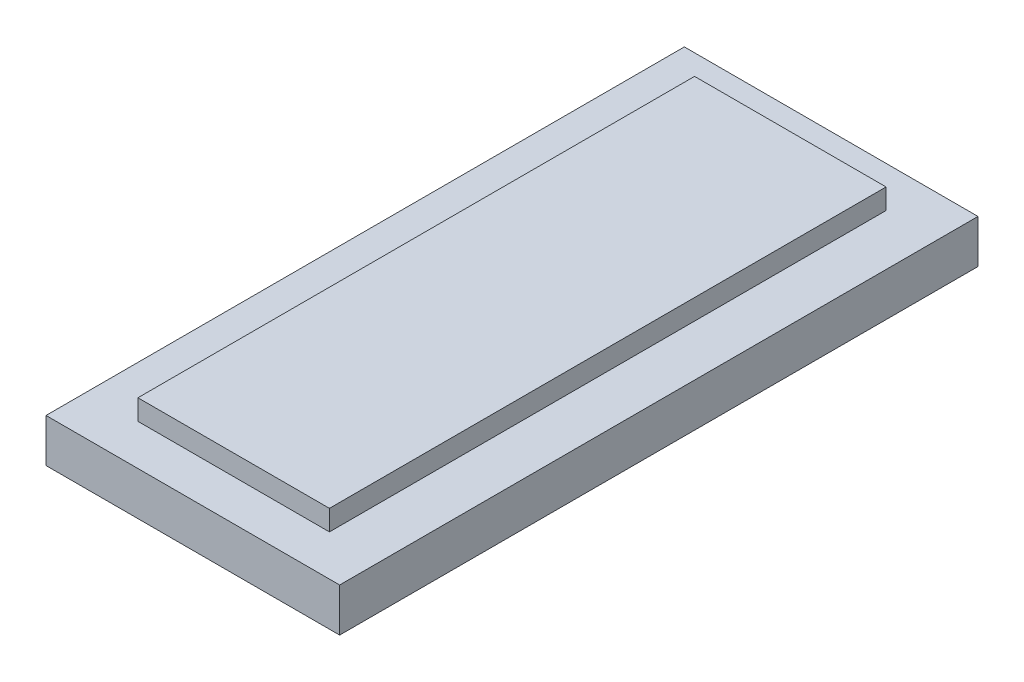
from build123d import *

# Parameters (mm, degrees)
SKETCH1_W           = 36.5125
SKETCH1_H           = 79.375
BOSS_EXTRUDE1_DEPTH = 7.9375
SKETCH2_W           = 36.5125
SKETCH2_H           = 79.375
SKETCH2_W_2         = 23.8125
SKETCH2_H_2         = 69.215
CUT_EXTRUDE1_DEPTH  = 2.54


with BuildPart() as part:
    # Sketch1 → Boss-Extrude1 (new body)
    with BuildSketch(Plane(origin=(0, 0, 0), x_dir=(1, 0, 0), z_dir=(0, 1, 0))):
        with Locations((18.25625, 39.6875)):
            Rectangle(SKETCH1_W, SKETCH1_H)
    extrude(amount=BOSS_EXTRUDE1_DEPTH)

    # Sketch2 → Cut-Extrude1 (cut)
    with BuildSketch(Plane(origin=(0, 7.9375, 0), x_dir=(1, 0, 0), z_dir=(0, 1, 0))):
        with Locations((18.25625, 39.6875)):
            Rectangle(SKETCH2_W, SKETCH2_H)
        with Locations((18.25625, 39.6875)):
            Rectangle(SKETCH2_W_2, SKETCH2_H_2, mode=Mode.SUBTRACT)
    extrude(amount=-CUT_EXTRUDE1_DEPTH, mode=Mode.SUBTRACT)


solid = part.part
